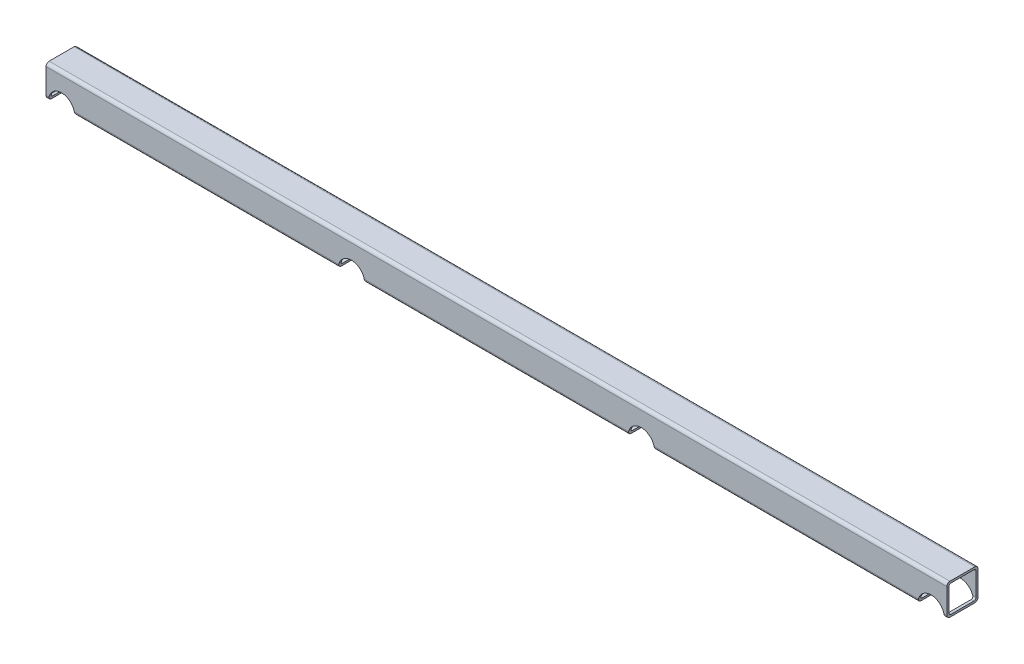
from build123d import *

# Parameters (mm, degrees)
EXTRUDE_1_DEPTH      = 850.470859
EXTRUDE_1_DEPTH_BACK = 15
SKETCH_3_R           = 12.6
CUT_EXTRUDE_1_DEPTH  = 31


with BuildPart() as part:
    # Эскиз2 → Бобышка-Вытянуть1 (new body, two sides)
    with BuildSketch(Plane(origin=(0, 0, 0), x_dir=(0, 0, -1), z_dir=(1, 0, 0))) as extrude_1_sk:
        with BuildLine():
            Line((-12, 30), (12, 30))
            ThreePointArc((12, 30), (14.121320344, 29.121320344), (15, 27))
            Line((15, 27), (15, 3))
            ThreePointArc((15, 3), (14.121320344, 0.878679656), (12, 0))
            Line((12, 0), (-12, 0))
            ThreePointArc((-12, 0), (-14.121320344, 0.878679656), (-15, 3))
            Line((-15, 3), (-15, 27))
            ThreePointArc((-15, 27), (-14.121320344, 29.121320344), (-12, 30))
        make_face()
        with BuildLine():
            Line((-11, 28), (11, 28))
            ThreePointArc((11, 28), (12.414213562, 27.414213562), (13, 26))
            Line((13, 26), (13, 4))
            ThreePointArc((13, 4), (12.414213562, 2.585786438), (11, 2))
            Line((11, 2), (-11, 2))
            ThreePointArc((-11, 2), (-12.414213562, 2.585786438), (-13, 4))
            Line((-13, 4), (-13, 26))
            ThreePointArc((-13, 26), (-12.414213562, 27.414213562), (-11, 28))
        make_face(mode=Mode.SUBTRACT)
    extrude(amount=EXTRUDE_1_DEPTH)
    extrude(extrude_1_sk.sketch, amount=-EXTRUDE_1_DEPTH_BACK)

    # Эскиз3 → Вырез-Вытянуть1 (cut, through all)
    with BuildSketch(Plane.XY.offset(15)):
        Circle(SKETCH_3_R)
        with Locations((278.490286217, 0)):
            Circle(SKETCH_3_R)
        with Locations((556.980572433, 0)):
            Circle(SKETCH_3_R)
        with Locations((835.47085865, 0)):
            Circle(SKETCH_3_R)
    extrude(amount=-CUT_EXTRUDE_1_DEPTH, mode=Mode.SUBTRACT)


solid = part.part
